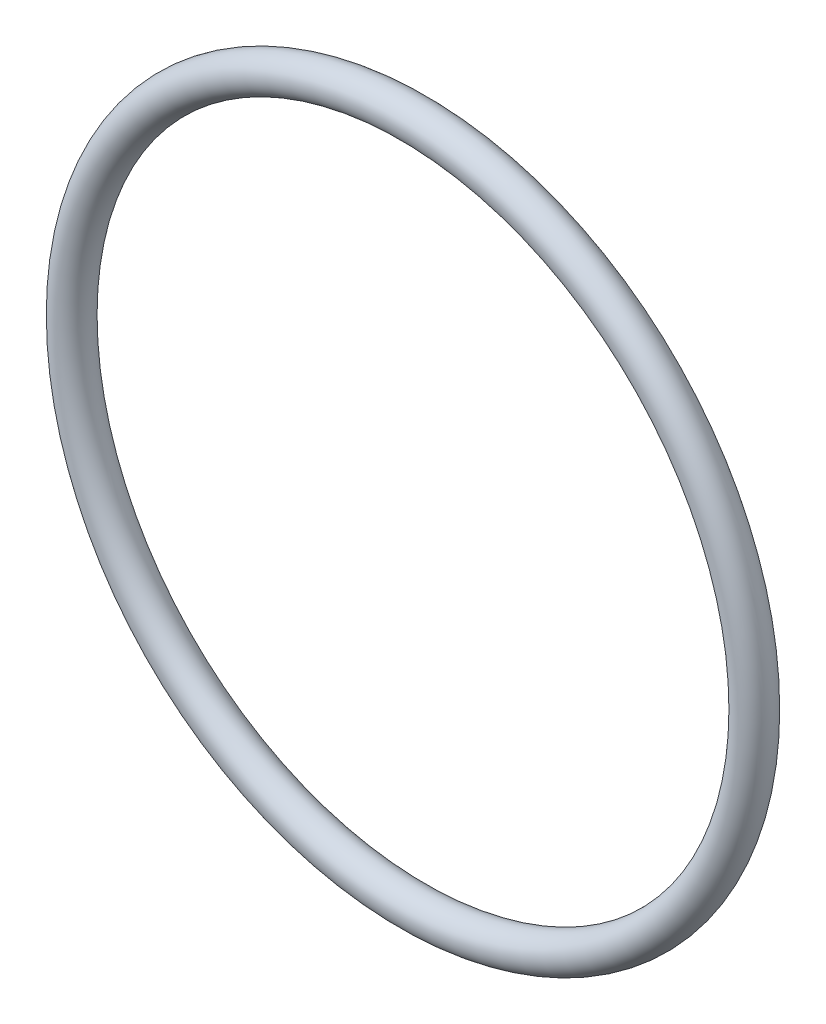
from build123d import *

# Parameters (mm, degrees)
ESQUISSE1_R = 0.75


with BuildPart() as part:
    # Esquisse1 → Révolution1 (revolve)
    with BuildSketch(Plane(origin=(0, 0, 0), x_dir=(0, 0, -1), z_dir=(1, 0, 0))):
        with Locations((0, 14.25)):
            Circle(ESQUISSE1_R)
    revolve(axis=Axis((0, 0, 0), (0, 0, -1)))


solid = part.part
